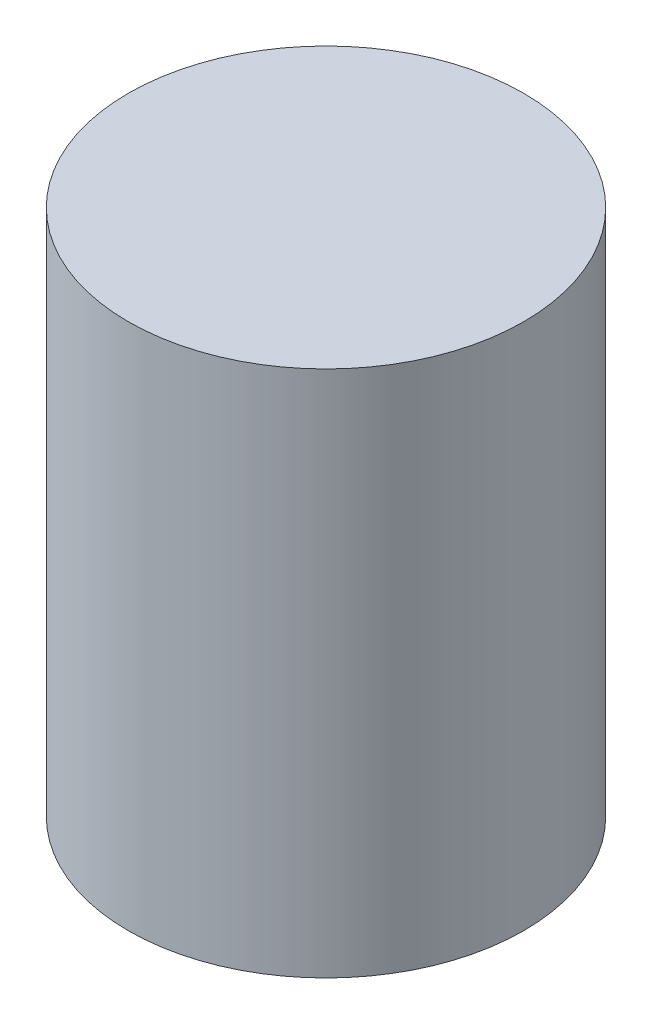
from build123d import *

# Parameters (mm, degrees)
SKETCH1_R                   = 28.575
BOSS_EXTRUDE1_DEPTH         = 76.2
F_1_2_13_TAPPED_HOLE1_D     = 10.71626
F_1_2_13_TAPPED_HOLE1_DEPTH = 40
F_1_2_13_TAPPED_HOLE1_TIP   = 3.219489309


with BuildPart() as part:
    # Sketch1 → Boss-Extrude1 (new body)
    with BuildSketch(Plane(origin=(0, 0, 0), x_dir=(1, 0, 0), z_dir=(0, 1, 0))):
        Circle(SKETCH1_R)
    extrude(amount=BOSS_EXTRUDE1_DEPTH)

    # 1/2-13 Tapped Hole1
    with Locations(Plane.XZ):
        with Locations((0, 0)):
            Hole(F_1_2_13_TAPPED_HOLE1_D / 2, depth=F_1_2_13_TAPPED_HOLE1_DEPTH)
            with Locations((0, 0, -(F_1_2_13_TAPPED_HOLE1_DEPTH + F_1_2_13_TAPPED_HOLE1_TIP / 2))):  # 118° drill point
                Cone(0, F_1_2_13_TAPPED_HOLE1_D / 2, F_1_2_13_TAPPED_HOLE1_TIP, mode=Mode.SUBTRACT)


solid = part.part
